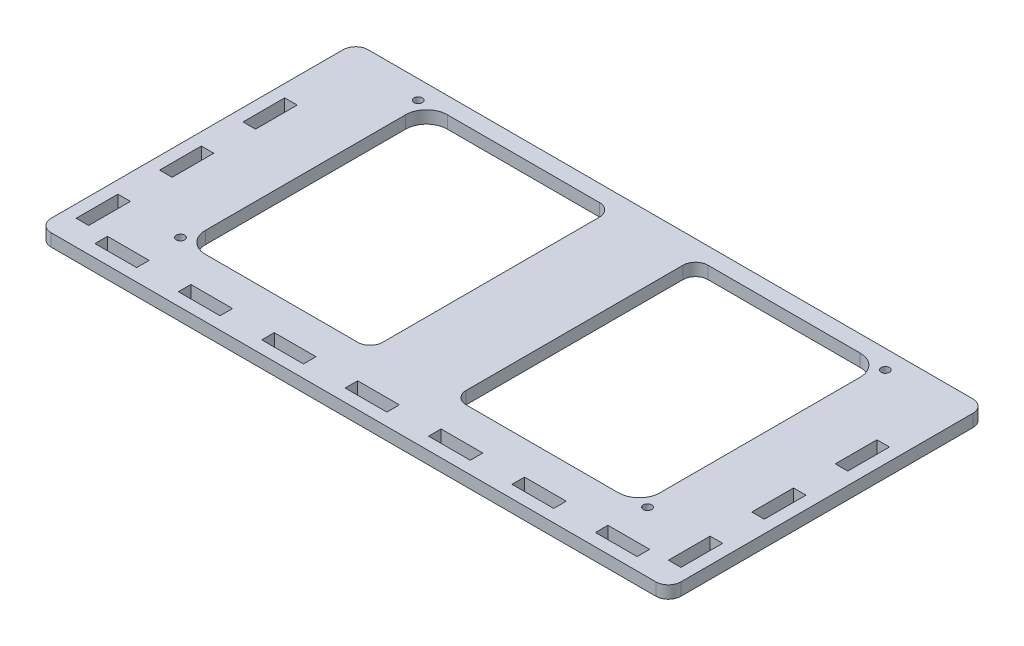
from build123d import *

# Parameters (mm, degrees)
SKETCH1_W           = 121
SKETCH1_H           = 66
BOSS_EXTRUDE1_DEPTH = 3
SKETCH2_W           = 109
SKETCH2_H           = 58
CUT_EXTRUDE1_DEPTH  = 4
FILLET1_R           = 5
SKETCH3_W           = 20
SKETCH3_H           = 58
BOSS_EXTRUDE2_DEPTH = 3
FILLET2_R           = 3
SKETCH4_R           = 1
CUT_EXTRUDE2_DEPTH  = 4
BOSS_EXTRUDE3_DEPTH = 3
FILLET3_R           = 3
SKETCH6_W           = 3
SKETCH6_H           = 10
SKETCH6_W_2         = 10
SKETCH6_H_2         = 3
CUT_EXTRUDE3_DEPTH  = 4


with BuildPart() as part:
    # Sketch1 → Boss-Extrude1 (new body)
    with BuildSketch(Plane(origin=(0, 0, 0), x_dir=(1, 0, 0), z_dir=(0, 1, 0))):
        with Locations((60.5, -33)):
            Rectangle(SKETCH1_W, SKETCH1_H)
    extrude(amount=BOSS_EXTRUDE1_DEPTH)

    # Sketch2 → Cut-Extrude1 (cut, through all)
    with BuildSketch(Plane(origin=(0, 3, 0), x_dir=(1, 0, 0), z_dir=(0, 1, 0))):
        with Locations((60.5, -33)):
            Rectangle(SKETCH2_W, SKETCH2_H)
    extrude(amount=-CUT_EXTRUDE1_DEPTH, mode=Mode.SUBTRACT)

    # Fillet1
    fillet1_edges = [part.edges().sort_by_distance(p)[0] for p in [
        (115, 1.5, 4),
        (115, 1.5, 62),
        (6, 1.5, 62),
        (6, 1.5, 4),
    ]]
    fillet(fillet1_edges, radius=FILLET1_R)

    # Sketch3 → Boss-Extrude2 (add, through all)
    with BuildSketch(Plane(origin=(0, 3, 0), x_dir=(1, 0, 0), z_dir=(0, 1, 0))):
        with Locations((60.5, -33)):
            Rectangle(SKETCH3_W, SKETCH3_H)
    extrude(amount=-BOSS_EXTRUDE2_DEPTH)

    # Fillet2
    fillet2_edges = [part.edges().sort_by_distance(p)[0] for p in [
        (70.5, 1.5, 4),
        (70.5, 1.5, 62),
        (50.5, 1.5, 62),
        (50.5, 1.5, 4),
    ]]
    fillet(fillet2_edges, radius=FILLET2_R)

    # Sketch4 → Cut-Extrude2 (cut, through all)
    with BuildSketch(Plane(origin=(0, 3, 0), x_dir=(1, 0, 0), z_dir=(0, 1, 0))):
        with Locations((116.5, -61.5)):
            Circle(SKETCH4_R)
        with Locations((116.5, -4.5)):
            Circle(SKETCH4_R)
        with Locations((4.5, -4.5)):
            Circle(SKETCH4_R)
        with Locations((4.5, -61.5)):
            Circle(SKETCH4_R)
    extrude(amount=-CUT_EXTRUDE2_DEPTH, mode=Mode.SUBTRACT)

    # Sketch5 → Boss-Extrude3 (add, through all)
    with BuildSketch(Plane(origin=(0, 3, 0), x_dir=(1, 0, 0), z_dir=(0, 1, 0))):
        Polygon((0, 0), (-15, 0), (-15, -76), (136, -76), (136, 0), (121, 0), (121, -66), (0, -66), align=None)
    extrude(amount=-BOSS_EXTRUDE3_DEPTH)

    # Fillet3
    fillet3_edges = [part.edges().sort_by_distance(p)[0] for p in [
        (136, 1.5, 0),
        (136, 1.5, 76),
        (-15, 1.5, 76),
        (-15, 1.5, 0),
    ]]
    fillet(fillet3_edges, radius=FILLET3_R)

    # Sketch6 → Cut-Extrude3 (cut, through all)
    with BuildSketch(Plane.XZ):
        with Locations((131.5, 25)):
            Rectangle(SKETCH6_W, SKETCH6_H)
        with Locations((131.5, 45)):
            Rectangle(SKETCH6_W, SKETCH6_H)
        with Locations((131.5, 65)):
            Rectangle(SKETCH6_W, SKETCH6_H)
        with Locations((120.5, 71.5)):
            Rectangle(SKETCH6_W_2, SKETCH6_H_2)
        with Locations((100.5, 71.5)):
            Rectangle(SKETCH6_W_2, SKETCH6_H_2)
        with Locations((80.5, 71.5)):
            Rectangle(SKETCH6_W_2, SKETCH6_H_2)
        with Locations((60.5, 71.5)):
            Rectangle(SKETCH6_W_2, SKETCH6_H_2)
        with Locations((40.5, 71.5)):
            Rectangle(SKETCH6_W_2, SKETCH6_H_2)
        with Locations((20.5, 71.5)):
            Rectangle(SKETCH6_W_2, SKETCH6_H_2)
        with Locations((0.5, 71.5)):
            Rectangle(SKETCH6_W_2, SKETCH6_H_2)
        with Locations((-10.5, 65)):
            Rectangle(SKETCH6_W, SKETCH6_H)
        with Locations((-10.5, 45)):
            Rectangle(SKETCH6_W, SKETCH6_H)
        with Locations((-10.5, 25)):
            Rectangle(SKETCH6_W, SKETCH6_H)
    extrude(amount=-CUT_EXTRUDE3_DEPTH, mode=Mode.SUBTRACT)


solid = part.part
